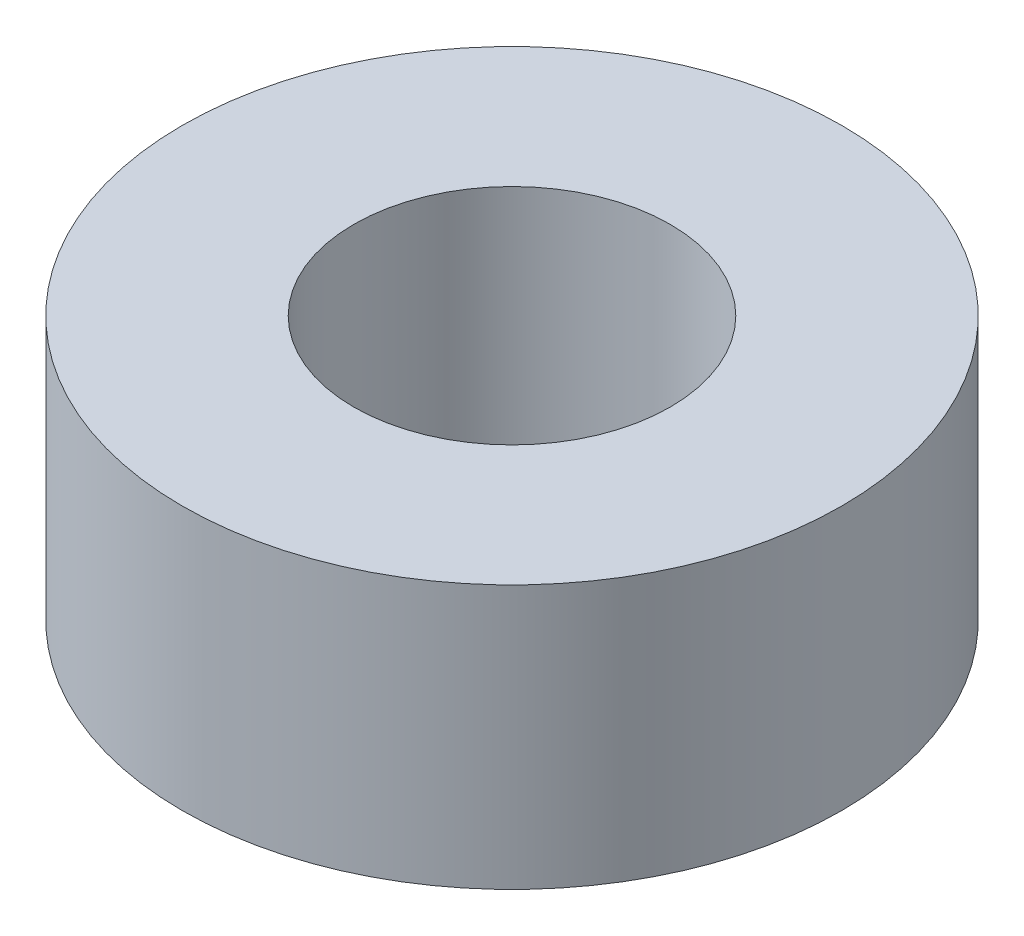
from build123d import *

# Parameters (mm, degrees)
SKETCH1_R           = 5
SKETCH1_R_2         = 2.4
BOSS_EXTRUDE1_DEPTH = 4


with BuildPart() as part:
    # Sketch1 → Boss-Extrude1 (new body)
    with BuildSketch(Plane(origin=(0, 0, 0), x_dir=(1, 0, 0), z_dir=(0, 1, 0))):
        Circle(SKETCH1_R)
        Circle(SKETCH1_R_2, mode=Mode.SUBTRACT)
    extrude(amount=BOSS_EXTRUDE1_DEPTH)


solid = part.part
